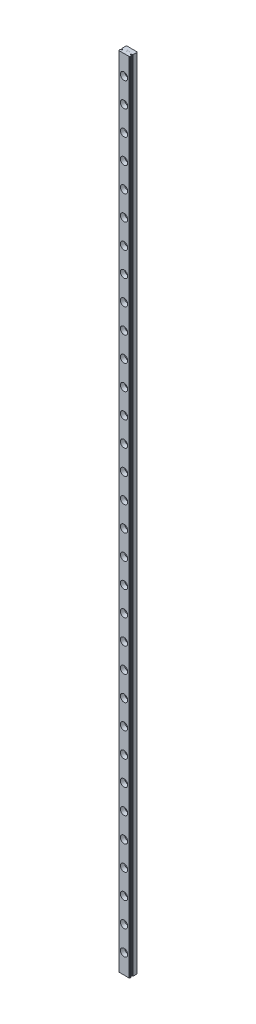
from build123d import *

# Parameters (mm, degrees)
SALIENTE_EXTRUIR1_DEPTH = 652
CORTAR_EXTRUIR1_DEPTH   = 653
CORTAR_EXTRUIR2_DEPTH   = 653
CORTAR_EXTRUIR3_DEPTH   = 653
CORTAR_EXTRUIR4_DEPTH   = 653
CORTAR_EXTRUIR5_DEPTH   = 653
CORTAR_EXTRUIR6_DEPTH   = 653
CORTAR_EXTRUIR7_DEPTH   = 0.002166667
CORTAR_EXTRUIR8_DEPTH   = 0.002166667
CORTAR_EXTRUIR9_DEPTH   = 0.002166667
CORTAR_EXTRUIR10_DEPTH  = 0.002166667
NGULO_DE_SALIDA1_ANGLE  = 45.1469538
CHAFL_N1_SIZE           = 0.4
REDONDEO1_R             = 0.130000023
MATRIZL2_COUNT          = 32
MATRIZL2_PITCH          = 20


with BuildPart() as part:
    # Croquis1 → Saliente-Extruir1 (new body)
    with BuildSketch(Plane.XZ):
        Polygon((4.5, 0), (4.5, 6.01167813), (4.1, 6.50000002), (-4.1, 6.50000002), (-4.5, 6.01167813), (-4.5, 0), align=None)
    extrude(amount=-SALIENTE_EXTRUIR1_DEPTH)

    # Croquis2 → Cortar-Extruir1 (cut, through all)
    with BuildSketch(Plane(origin=(0, 652, 0), x_dir=(-1, 0, 0), z_dir=(0, 1, 0))):
        with BuildLine():
            Line((-4.5, 4.88017535), (-4.5, 4.03150278))
            Line((-4.5, 4.03150278), (-3.819258765, 4.03150278))
            ThreePointArc((-3.819258765, 4.03150278), (-3.21946318, 4.455839065), (-3.819258765, 4.88017535))
            Line((-3.819258765, 4.88017535), (-4.5, 4.88017535))
        make_face()
    extrude(amount=-CORTAR_EXTRUIR1_DEPTH, mode=Mode.SUBTRACT)

    # Croquis3 → Cortar-Extruir2 (cut, through all)
    with BuildSketch(Plane(origin=(0, 652, 0), x_dir=(-1, 0, 0), z_dir=(0, 1, 0))):
        with BuildLine():
            Line((-4.026513856, 4.03150278), (-4.5, 4.03150278))
            Line((-4.5, 4.03150278), (-4.5, 3.583620931))
            ThreePointArc((-4.5, 3.583620931), (-4.223645982, 3.76568645), (-4.026513856, 4.03150278))
        make_face()
    extrude(amount=-CORTAR_EXTRUIR2_DEPTH, mode=Mode.SUBTRACT)

    # Croquis4 → Cortar-Extruir3 (cut, through all)
    with BuildSketch(Plane(origin=(0, 652, 0), x_dir=(-1, 0, 0), z_dir=(0, 1, 0))):
        with BuildLine():
            Line((-4.5, 5.328056964), (-4.5, 4.88017535))
            Line((-4.5, 4.88017535), (-4.026513974, 4.88017535))
            ThreePointArc((-4.026513974, 4.88017535), (-4.223646078, 5.145991535), (-4.5, 5.328056964))
        make_face()
    extrude(amount=-CORTAR_EXTRUIR3_DEPTH, mode=Mode.SUBTRACT)

    # Croquis5 → Cortar-Extruir4 (cut, through all)
    with BuildSketch(Plane(origin=(0, 652, 0), x_dir=(-1, 0, 0), z_dir=(0, 1, 0))):
        with BuildLine():
            Line((4.5, 4.03150278), (4.5, 4.88017535))
            Line((4.5, 4.88017535), (3.819258765, 4.88017535))
            ThreePointArc((3.819258765, 4.88017535), (3.21946318, 4.455839065), (3.819258765, 4.03150278))
            Line((3.819258765, 4.03150278), (4.5, 4.03150278))
        make_face()
    extrude(amount=-CORTAR_EXTRUIR4_DEPTH, mode=Mode.SUBTRACT)

    # Croquis6 → Cortar-Extruir5 (cut, through all)
    with BuildSketch(Plane(origin=(0, 652, 0), x_dir=(-1, 0, 0), z_dir=(0, 1, 0))):
        with BuildLine():
            Line((4.026513826, 4.88017535), (4.5, 4.88017535))
            Line((4.5, 4.88017535), (4.5, 5.328057255))
            ThreePointArc((4.5, 5.328057255), (4.223645966, 5.145991706), (4.026513826, 4.88017535))
        make_face()
    extrude(amount=-CORTAR_EXTRUIR5_DEPTH, mode=Mode.SUBTRACT)

    # Croquis7 → Cortar-Extruir6 (cut, through all)
    with BuildSketch(Plane(origin=(0, 652, 0), x_dir=(-1, 0, 0), z_dir=(0, 1, 0))):
        with BuildLine():
            Line((4.5, 3.583620926), (4.5, 4.03150278))
            Line((4.5, 4.03150278), (4.026513851, 4.03150278))
            ThreePointArc((4.026513851, 4.03150278), (4.223645987, 3.765686455), (4.5, 3.583620926))
        make_face()
    extrude(amount=-CORTAR_EXTRUIR6_DEPTH, mode=Mode.SUBTRACT)

    # Croquis8 → Cortar-Extruir7 (cut)
    with BuildSketch(Plane(origin=(0, 652, 0), x_dir=(-1, 0, 0), z_dir=(0, 1, 0))):
        Polygon((0.891369267, 3.403698133), (0.714701433, 3.168235633), (0.2187042, 2.61105), (1.0945792, 2.61105), (1.0945792, 2.695983333), (0.398689633, 2.695983333), (0.794326433, 3.149466667), (0.9743123, 3.3891), (1.067110588, 3.573407857), (0.95413722, 3.802321701), (0.7876908, 3.88505), (0.54301, 3.88505), (0.375434678, 3.803592619), (0.295011167, 3.6384023), (0.295011167, 3.562), (0.3812718, 3.562), (0.3812718, 3.631766667), (0.437672733, 3.743620833), (0.549645633, 3.800116667), (0.7802262, 3.800116667), (0.893028067, 3.743810633), (0.976240026, 3.576039029), align=None)
    extrude(amount=-CORTAR_EXTRUIR7_DEPTH, mode=Mode.SUBTRACT)

    # Croquis9 → Cortar-Extruir8 (cut)
    with BuildSketch(Plane.XZ):
        Polygon((-0.214632167, 3.88505), (-0.953983333, 3.88505), (-0.953983333, 2.61105), (-0.214632167, 2.61105), (-0.214632167, 2.695983333), (-0.86905, 2.695983333), (-0.86905, 3.205583333), (-0.5123963, 3.205583333), (-0.5123963, 3.290516667), (-0.86905, 3.290516667), (-0.86905, 3.800116667), (-0.214632167, 3.800116667), align=None)
    extrude(amount=-CORTAR_EXTRUIR8_DEPTH, mode=Mode.SUBTRACT)

    # Croquis10 → Cortar-Extruir9 (cut)
    with BuildSketch(Plane(origin=(0, 652, 0), x_dir=(-1, 0, 0), z_dir=(0, 1, 0))):
        Polygon((-0.214632167, 3.88505), (-0.953983333, 3.88505), (-0.953983333, 2.61105), (-0.214632167, 2.61105), (-0.214632167, 2.695983333), (-0.86905, 2.695983333), (-0.86905, 3.205583333), (-0.5123963, 3.205583333), (-0.5123963, 3.290516667), (-0.86905, 3.290516667), (-0.86905, 3.800116667), (-0.214632167, 3.800116667), align=None)
    extrude(amount=-CORTAR_EXTRUIR9_DEPTH, mode=Mode.SUBTRACT)

    # Croquis11 → Cortar-Extruir10 (cut)
    with BuildSketch(Plane.XZ):
        Polygon((0.510057167, 3.620830633), (0.6071, 3.718655633), (0.6071, 2.609403333), (0.692033333, 2.609403333), (0.692033333, 3.883403333), (0.6741176, 3.883403333), (0.6741176, 3.795069794), (0.3690544, 3.640736667), (0.3690544, 3.551253333), align=None)
    extrude(amount=-CORTAR_EXTRUIR10_DEPTH, mode=Mode.SUBTRACT)

    # Ángulo de salida1
    ngulo_de_salida1_faces = [part.faces().sort_by_distance(p)[0] for p in [
        (0.6741176, 0.001083333, 3.839236564),
    ]]
    draft(ngulo_de_salida1_faces, Plane(origin=(0.692033333, 0.002166667, 3.883403333), x_dir=(-1, 0, 0), z_dir=(0, 0, -1)), NGULO_DE_SALIDA1_ANGLE)

    # Chaflán1
    chafl_n1_edges = [part.edges().sort_by_distance(p)[0] for p in [
        (-4.5, 326, 0),
        (4.5, 326, 0),
    ]]
    chamfer(chafl_n1_edges, length=CHAFL_N1_SIZE)

    # Redondeo1
    redondeo1_edges = [part.edges().sort_by_distance(p)[0] for p in [
        (4.026513856, 326, 4.03150278),
        (4.5, 326, 3.583620931),
        (4.5, 326, 5.328056964),
        (4.026513974, 326, 4.88017535),
        (-4.026513826, 326, 4.88017535),
        (-4.5, 326, 5.328057255),
        (-4.5, 326, 3.583620926),
        (-4.026513851, 326, 4.03150278),
    ]]
    fillet(redondeo1_edges, radius=REDONDEO1_R)

    # Croquis34 → Taladro roscado M3.5x0.61 (revolve, cut)
    with BuildSketch(Plane(origin=(0, 16, 0), x_dir=(0, 1, 0), z_dir=(1, 0, 0))):
        Polygon((0, 0), (0, 8), (3, 8), (3, 3), (1.5, 3), (1.5, 0), align=None)
    taladro_roscado_m3_5x0_61 = revolve(axis=Axis((0, 16, -6.35), (0, 0, 1)), mode=Mode.SUBTRACT)

    # MatrizL2: Taladro roscado M3.5x0.61 ×32
    with Locations(*[(0, i * MATRIZL2_PITCH, 0) for i in range(1, MATRIZL2_COUNT)]):
        add(taladro_roscado_m3_5x0_61, mode=Mode.SUBTRACT)


solid = part.part
